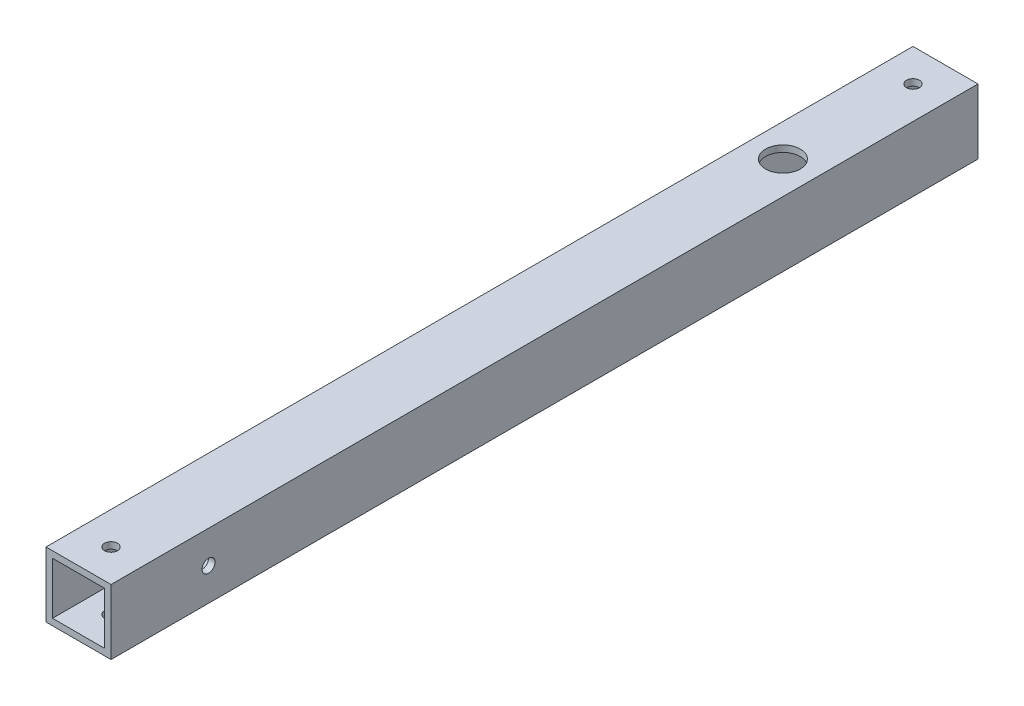
from build123d import *

# Parameters (mm, degrees)
SKETCH_1_W          = 15
SKETCH_1_H          = 15
SKETCH_1_W_2        = 12
SKETCH_1_H_2        = 12
EXTRUDE_2_DEPTH     = 200
SKETCH_2_R          = 1.5
CUT_EXTRUDE_1_DEPTH = 15
SKETCH_3_R          = 1.5
CUT_EXTRUDE_2_DEPTH = 15
SKETCH_4_R          = 1.5
SKETCH_4_R_2        = 4
CUT_EXTRUDE_6_DEPTH = 10
SKETCH_6_R          = 1.5
SKETCH_6_R_2        = 4
CUT_EXTRUDE_7_DEPTH = 10


with BuildPart() as part:
    # ｽｹｯﾁ1 → ﾎﾞｽ - 押し出し2 (new body)
    with BuildSketch(Plane.XY):
        with Locations((0.489915859, 0.232626086)):
            Rectangle(SKETCH_1_W, SKETCH_1_H)
        with Locations((0.489915859, 0.232626086)):
            Rectangle(SKETCH_1_W_2, SKETCH_1_H_2, mode=Mode.SUBTRACT)
    extrude(amount=EXTRUDE_2_DEPTH)

    # ｽｹｯﾁ2 → ｶｯﾄ - 押し出し1 (cut)
    with BuildSketch(Plane(origin=(0, 7.732626086, 0), x_dir=(1, 0, 0), z_dir=(0, 1, 0))):
        with Locations((0.489915859, -192.5)):
            Circle(SKETCH_2_R)
    extrude(amount=-CUT_EXTRUDE_1_DEPTH, mode=Mode.SUBTRACT)

    # ｽｹｯﾁ3 → ｶｯﾄ - 押し出し2 (cut)
    with BuildSketch(Plane(origin=(7.989915859, 0, 0), x_dir=(0, 0, -1), z_dir=(1, 0, 0))):
        with Locations((-177.5, 0.232626086)):
            Circle(SKETCH_3_R)
    extrude(amount=-CUT_EXTRUDE_2_DEPTH, mode=Mode.SUBTRACT)

    # ｽｹｯﾁ4 → ｶｯﾄ - 押し出し6 (cut)
    with BuildSketch(Plane(origin=(0, 7.732626086, 0), x_dir=(1, 0, 0), z_dir=(0, 1, 0))):
        with Locations((0.489915859, -7.5)):
            Circle(SKETCH_4_R)
        with Locations((0.489915859, -37.5)):
            Circle(SKETCH_4_R_2)
    extrude(amount=-CUT_EXTRUDE_6_DEPTH, mode=Mode.SUBTRACT)

    # ｽｹｯﾁ6 → ｶｯﾄ - 押し出し7 (cut)
    with BuildSketch(Plane.XZ.offset(7.267373914)):
        with Locations((0.489915859, 37.5)):
            Circle(SKETCH_6_R)
        with Locations((0.489915859, 7.5)):
            Circle(SKETCH_6_R_2)
    extrude(amount=-CUT_EXTRUDE_7_DEPTH, mode=Mode.SUBTRACT)


solid = part.part
